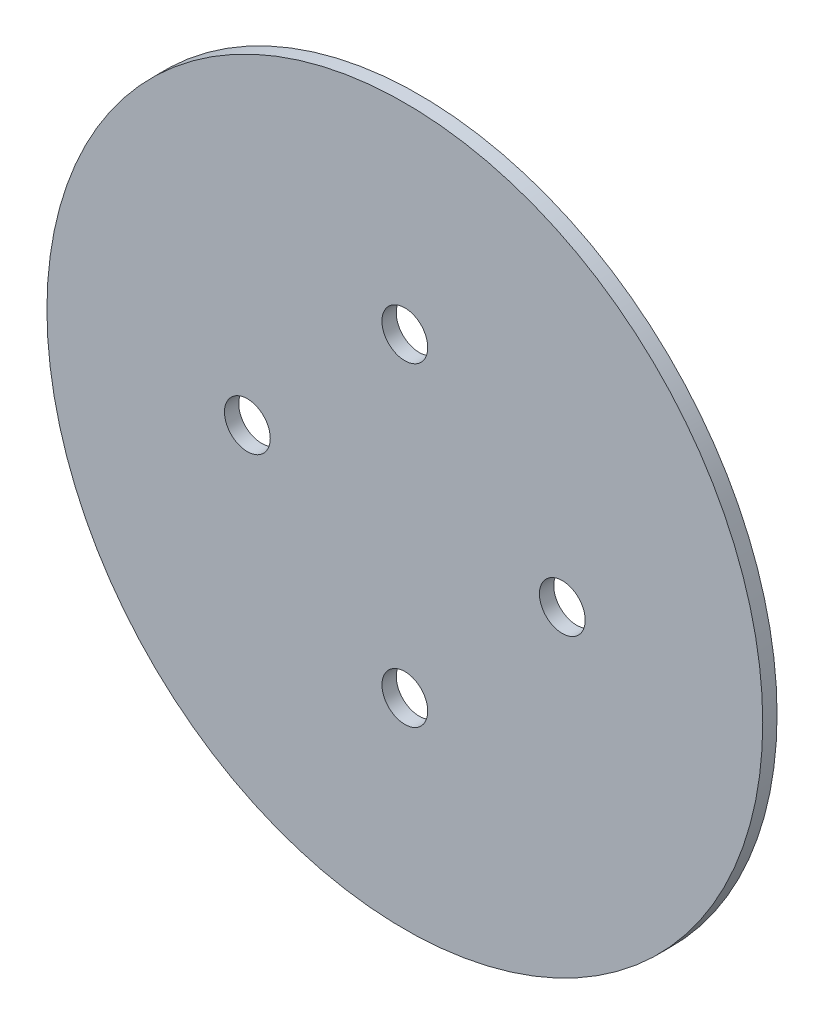
from build123d import *

# Parameters (mm, degrees)
SKETCH1_R           = 25
SKETCH1_R_2         = 1.6
BOSS_EXTRUDE1_DEPTH = 1


with BuildPart() as part:
    # Sketch1 → Boss-Extrude1 (new body)
    with BuildSketch(Plane(origin=(0, 0, 0), x_dir=(0, 1, 0), z_dir=(0, 0, 1))):
        Circle(SKETCH1_R)
        with Locations((0, 11)):
            Circle(SKETCH1_R_2, mode=Mode.SUBTRACT)
        with Locations((11, 0)):
            Circle(SKETCH1_R_2, mode=Mode.SUBTRACT)
        with Locations((0, -11)):
            Circle(SKETCH1_R_2, mode=Mode.SUBTRACT)
        with Locations((-11, 0)):
            Circle(SKETCH1_R_2, mode=Mode.SUBTRACT)
    extrude(amount=BOSS_EXTRUDE1_DEPTH)


solid = part.part
